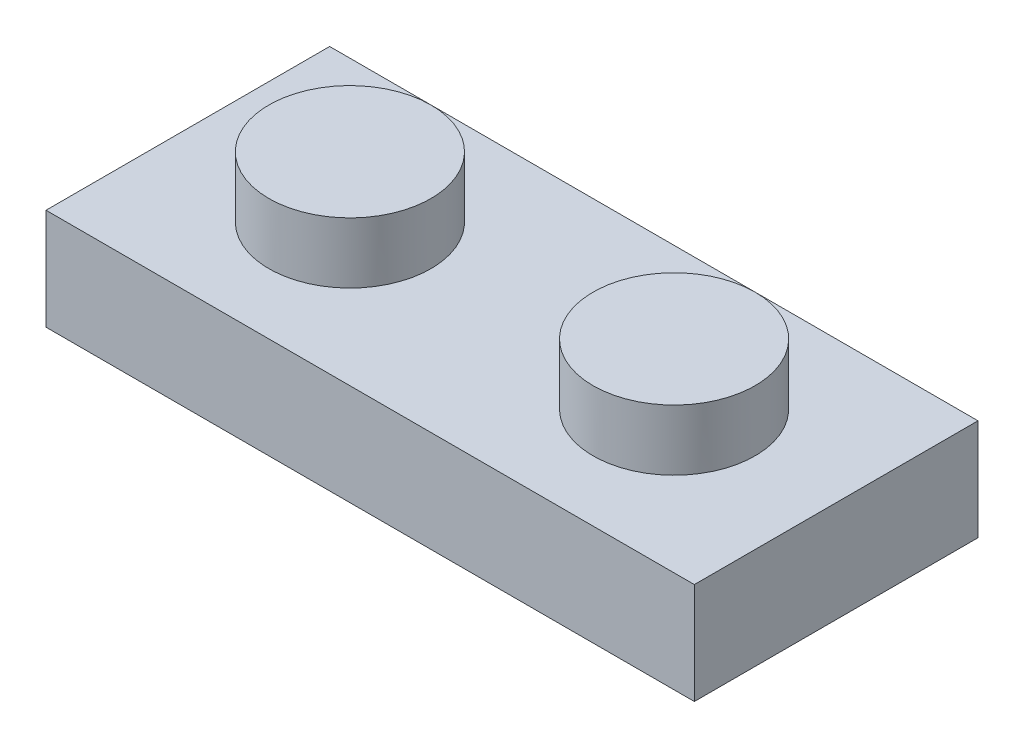
from build123d import *

# Parameters (mm, degrees)
SKETCH1_W           = 20.32
SKETCH1_H           = 3.175
BOSS_EXTRUDE2_DEPTH = 4.445
SKETCH3_R           = 2.54
BOSS_EXTRUDE3_DEPTH = 1.905
SKETCH4_W           = 17.78
SKETCH4_H           = 5.08
CUT_EXTRUDE1_DEPTH  = 1.905
SKETCH5_R           = 1.905
CUT_EXTRUDE2_DEPTH  = 2.54
SKETCH6_R           = 1.905
SKETCH6_R_2         = 0.9525
BOSS_EXTRUDE4_DEPTH = 1.905


with BuildPart() as part:
    # Sketch1 → Boss-Extrude2 (new body, symmetric)
    with BuildSketch(Plane.XY):
        with Locations((0, -1.5875)):
            Rectangle(SKETCH1_W, SKETCH1_H)
    extrude(amount=BOSS_EXTRUDE2_DEPTH, both=True)

    # Sketch3 → Boss-Extrude3 (add)
    with BuildSketch(Plane(origin=(0, 0, 0), x_dir=(1, 0, 0), z_dir=(0, 1, 0))):
        with Locations((-5.08, 0)):
            Circle(SKETCH3_R)
        with Locations((5.08, 0)):
            Circle(SKETCH3_R)
    extrude(amount=BOSS_EXTRUDE3_DEPTH)

    # Sketch4 → Cut-Extrude1 (cut)
    with BuildSketch(Plane.XZ.offset(3.175)):
        Rectangle(SKETCH4_W, SKETCH4_H)
    extrude(amount=-CUT_EXTRUDE1_DEPTH, mode=Mode.SUBTRACT)

    # Sketch5 → Cut-Extrude2 (cut)
    with BuildSketch(Plane.XZ.offset(1.27)):
        with Locations((-5.08, 0)):
            Circle(SKETCH5_R)
        with Locations((5.08, 0)):
            Circle(SKETCH5_R)
    extrude(amount=-CUT_EXTRUDE2_DEPTH, mode=Mode.SUBTRACT)

    # Sketch6 → Boss-Extrude4 (add)
    with BuildSketch(Plane.XZ.offset(1.27)):
        Circle(SKETCH6_R)
        Circle(SKETCH6_R_2, mode=Mode.SUBTRACT)
    extrude(amount=BOSS_EXTRUDE4_DEPTH)


solid = part.part
